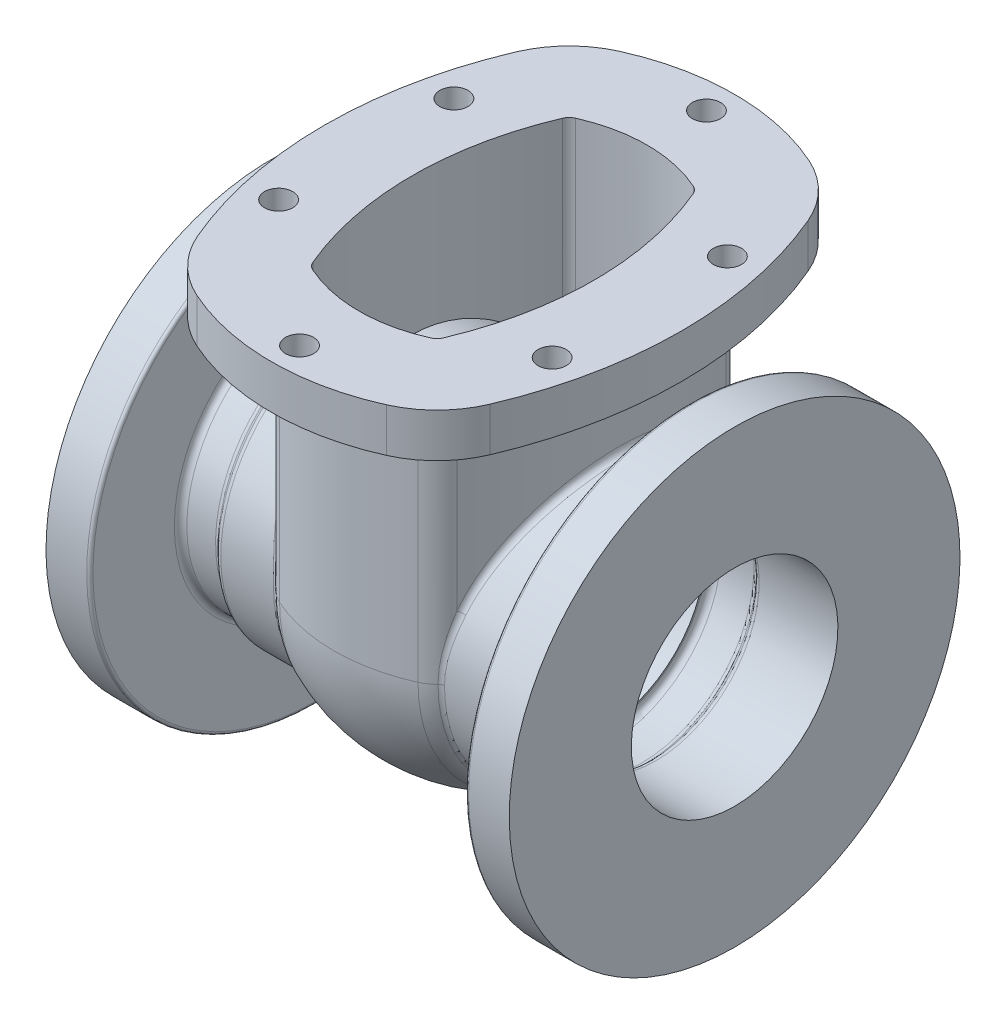
from build123d import *

# Parameters (mm, degrees)
SKETCH1_R                       = 7.14375
BOSS_EXTRUDE1_DEPTH             = 22.225
BOSS_EXTRUDE2_DEPTH             = 120.65
REVOLVE1_ANGLE                  = 180
SKETCH3_R                       = 51.59375
CUT_EXTRUDE3_DEPTH              = 288.753807533
CUT_EXTRUDE3_DEPTH_BACK         = 288.753807533
FILLET1_R                       = 3.175
BOSS_EXTRUDE3_REACH             = 289.754
SKETCH10_R                      = 73.025
SKETCH10_R_2                    = 60.325
BOSS_EXTRUDE3_DIRECTION_2_REACH = 289.754
FILLET4_R                       = 3.175


with BuildPart() as part:
    # Sketch1 → Boss-Extrude1 (new body)
    with BuildSketch(Plane(origin=(0, 0, 0), x_dir=(1, 0, 0), z_dir=(0, 1, 0))):
        with BuildLine():
            ThreePointArc((-74.058849944, -80.690921224), (-90.4875, 0), (-74.058849944, 80.690921224))
            ThreePointArc((-74.058849944, 80.690921224), (-63.584590133, 96.385165084), (-48.104977984, 107.174095369))
            ThreePointArc((-48.104977984, 107.174095369), (0, 117.475), (48.104977984, 107.174095369))
            ThreePointArc((48.104977984, 107.174095369), (63.584590133, 96.385165084), (74.058849944, 80.690921224))
            ThreePointArc((74.058849944, 80.690921224), (90.4875, 0), (74.058849944, -80.690921224))
            ThreePointArc((74.058849944, -80.690921224), (63.584590133, -96.385165084), (48.104977984, -107.174095369))
            ThreePointArc((48.104977984, -107.174095369), (0, -117.475), (-48.104977984, -107.174095369))
            ThreePointArc((-48.104977984, -107.174095369), (-63.584590133, -96.385165084), (-74.058849944, -80.690921224))
        make_face()
        with Locations(Location((0, 103.1875, 0), (0, 0, 270))):
            Circle(SKETCH1_R, mode=Mode.SUBTRACT)
        with Locations(Location((69.354092252, 44.45, 0), (0, 0, 270))):
            Circle(SKETCH1_R, mode=Mode.SUBTRACT)
        with Locations(Location((69.354092252, -44.45, 0), (0, 0, 90))):
            Circle(SKETCH1_R, mode=Mode.SUBTRACT)
        with Locations(Location((0, -103.1875, 0), (0, 0, 90))):
            Circle(SKETCH1_R, mode=Mode.SUBTRACT)
        with Locations(Location((-69.354092252, 44.45, 0), (0, 0, 90))):
            Circle(SKETCH1_R, mode=Mode.SUBTRACT)
        with Locations(Location((-69.354092252, -44.45, 0), (0, 0, 270))):
            Circle(SKETCH1_R, mode=Mode.SUBTRACT)
        with BuildLine():
            ThreePointArc((-29.903094423, 66.621734959), (0, 73.025), (29.903094423, 66.621734959))
            ThreePointArc((29.903094423, 66.621734959), (31.838045941, 65.273118673), (33.147328418, 63.311338191))
            ThreePointArc((33.147328418, 63.311338191), (46.0375, 0), (33.147328418, -63.311338191))
            ThreePointArc((33.147328418, -63.311338191), (31.838045941, -65.273118673), (29.903094423, -66.621734959))
            ThreePointArc((29.903094423, -66.621734959), (0, -73.025), (-29.903094423, -66.621734959))
            ThreePointArc((-29.903094423, -66.621734959), (-31.838045941, -65.273118673), (-33.147328418, -63.311338191))
            ThreePointArc((-33.147328418, -63.311338191), (-46.0375, 0), (-33.147328418, 63.311338191))
            ThreePointArc((-33.147328418, 63.311338191), (-31.838045941, 65.273118673), (-29.903094423, 66.621734959))
        make_face(mode=Mode.SUBTRACT)
    extrude(amount=BOSS_EXTRUDE1_DEPTH)

    # Sketch4 → Boss-Extrude2 (add)
    with BuildSketch(Plane.XZ):
        with BuildLine():
            ThreePointArc((44.836334568, -68.276933343), (58.7375, 0), (44.836334568, 68.276933343))
            ThreePointArc((44.836334568, 68.276933343), (40.908487139, 74.162274791), (35.103632583, 78.208123648))
            ThreePointArc((35.103632583, 78.208123648), (0, 85.725), (-35.103632583, 78.208123648))
            ThreePointArc((-35.103632583, 78.208123648), (-40.908487139, 74.162274791), (-44.836334568, 68.276933343))
            ThreePointArc((-44.836334568, 68.276933343), (-58.7375, 0), (-44.836334568, -68.276933343))
            ThreePointArc((-44.836334568, -68.276933343), (-40.908487139, -74.162274791), (-35.103632583, -78.208123648))
            ThreePointArc((-35.103632583, -78.208123648), (0, -85.725), (35.103632583, -78.208123648))
            ThreePointArc((35.103632583, -78.208123648), (40.908487139, -74.162274791), (44.836334568, -68.276933343))
        make_face()
        with BuildLine():
            ThreePointArc((-29.903094423, 66.621734959), (-31.838045941, 65.273118673), (-33.147328418, 63.311338191))
            ThreePointArc((-33.147328418, 63.311338191), (-46.0375, 0), (-33.147328418, -63.311338191))
            ThreePointArc((-33.147328418, -63.311338191), (-31.838045941, -65.273118673), (-29.903094423, -66.621734959))
            ThreePointArc((-29.903094423, -66.621734959), (0, -73.025), (29.903094423, -66.621734959))
            ThreePointArc((29.903094423, -66.621734959), (31.838045941, -65.273118673), (33.147328418, -63.311338191))
            ThreePointArc((33.147328418, -63.311338191), (46.0375, 0), (33.147328418, 63.311338191))
            ThreePointArc((33.147328418, 63.311338191), (31.838045941, 65.273118673), (29.903094423, 66.621734959))
            ThreePointArc((29.903094423, 66.621734959), (0, 73.025), (-29.903094423, 66.621734959))
        make_face(mode=Mode.SUBTRACT)
    extrude(amount=BOSS_EXTRUDE2_DEPTH)

    # Sketch5 → Revolve1 (revolve)
    with BuildSketch(Plane.XZ.offset(120.65)):
        with BuildLine():
            Line((58.7375, 0), (46.0375, 0))
            ThreePointArc((46.0375, 0), (42.782235956, 32.305115953), (33.147328418, 63.311338191))
            ThreePointArc((33.147328418, 63.311338191), (31.838045941, 65.273118673), (29.903094423, 66.621734959))
            ThreePointArc((29.903094423, 66.621734959), (0, 73.025), (-29.903094423, 66.621734959))
            ThreePointArc((-29.903094423, 66.621734959), (-31.838045941, 65.273118673), (-33.147328418, 63.311338191))
            ThreePointArc((-33.147328418, 63.311338191), (-42.782235956, 32.305115953), (-46.0375, 0))
            Line((-46.0375, 0), (-58.7375, 0))
            ThreePointArc((-58.7375, 0), (-55.226921129, 34.838850538), (-44.836334568, 68.276933343))
            ThreePointArc((-44.836334568, 68.276933343), (-40.908487139, 74.162274791), (-35.103632583, 78.208123648))
            ThreePointArc((-35.103632583, 78.208123648), (0, 85.725), (35.103632583, 78.208123648))
            ThreePointArc((35.103632583, 78.208123648), (40.908487139, 74.162274791), (44.836334568, 68.276933343))
            ThreePointArc((44.836334568, 68.276933343), (55.226921129, 34.838850538), (58.7375, 0))
        make_face()
    revolve(axis=Axis((58.7375, -120.65, 0), (1, 0, 0)), revolution_arc=REVOLVE1_ANGLE)

    # Sketch6 → Revolve2 (revolve)
    with BuildSketch(Plane.XY):
        with BuildLine():
            Line((96.8375, -234.95), (117.475, -234.95))
            Line((117.475, -234.95), (117.475, -173.0375))
            Line((117.475, -173.0375), (77.515128061, -173.0375))
            ThreePointArc((77.515128061, -173.0375), (76.300108163, -173.279182484), (75.27006403, -173.96743597))
            Line((75.27006403, -173.96743597), (72.36743597, -176.87006403))
            ThreePointArc((72.36743597, -176.87006403), (71.337391837, -177.558317516), (70.122371939, -177.8))
            Line((70.122371939, -177.8), (49.120888044, -177.8))
            ThreePointArc((49.120888044, -177.8), (47.073606935, -183.400045829), (44.836334568, -188.926933343))
            ThreePointArc((44.836334568, -188.926933343), (43.560758987, -191.40739219), (41.936651857, -193.675))
            Line((41.936651857, -193.675), (70.122371939, -193.675))
            ThreePointArc((70.122371939, -193.675), (71.337391837, -193.433317516), (72.36743597, -192.74506403))
            Line((72.36743597, -192.74506403), (75.27006403, -189.84243597))
            ThreePointArc((75.27006403, -189.84243597), (76.300108163, -189.154182484), (77.515128061, -188.9125))
            Line((77.515128061, -188.9125), (95.25, -188.9125))
            Line((95.25, -188.9125), (95.25, -233.3625))
            ThreePointArc((95.25, -233.3625), (95.714967985, -234.485032015), (96.8375, -234.95))
        make_face()
        with BuildLine():
            ThreePointArc((-44.836334568, -188.926933343), (-47.073606935, -183.400045829), (-49.120888044, -177.8))
            Line((-49.120888044, -177.8), (-70.122371939, -177.8))
            ThreePointArc((-70.122371939, -177.8), (-71.337391837, -177.558317516), (-72.36743597, -176.87006403))
            Line((-72.36743597, -176.87006403), (-75.27006403, -173.96743597))
            ThreePointArc((-75.27006403, -173.96743597), (-76.300108163, -173.279182484), (-77.515128061, -173.0375))
            Line((-77.515128061, -173.0375), (-117.475, -173.0375))
            Line((-117.475, -173.0375), (-117.475, -234.95))
            Line((-117.475, -234.95), (-96.8375, -234.95))
            ThreePointArc((-96.8375, -234.95), (-95.714967985, -234.485032015), (-95.25, -233.3625))
            Line((-95.25, -233.3625), (-95.25, -188.9125))
            Line((-95.25, -188.9125), (-77.515128061, -188.9125))
            ThreePointArc((-77.515128061, -188.9125), (-76.300108163, -189.154182484), (-75.27006403, -189.84243597))
            Line((-75.27006403, -189.84243597), (-72.36743597, -192.74506403))
            ThreePointArc((-72.36743597, -192.74506403), (-71.337391837, -193.433317516), (-70.122371939, -193.675))
            Line((-70.122371939, -193.675), (-41.936651857, -193.675))
            ThreePointArc((-41.936651857, -193.675), (-43.560758987, -191.40739219), (-44.836334568, -188.926933343))
        make_face()
    revolve(axis=Axis((0, -120.65, 0), (1, 0, 0)))

    # Sketch3 → Cut-Extrude3 (cut, two sides)
    with BuildSketch(Plane(origin=(0, 0, 0), x_dir=(0, 0, -1), z_dir=(1, 0, 0))) as cut_extrude3_sk:
        with Locations((0, -120.65)):
            Circle(SKETCH3_R)
    extrude(amount=CUT_EXTRUDE3_DEPTH, mode=Mode.SUBTRACT)
    extrude(cut_extrude3_sk.sketch, amount=-CUT_EXTRUDE3_DEPTH_BACK, mode=Mode.SUBTRACT)

    # Fillet1
    fillet1_edges = [part.edges().sort_by_distance(p)[0] for p in [
        (49.120888044, -161.061152545, -40.411152545),
        (58.737500008, -63.500000001, -3e-07),
        (-49.120888044, -161.061152545, 40.411152545),
        (-58.737500001, -63.500000011, 3e-07),
    ]]
    fillet(fillet1_edges, radius=FILLET1_R)

    # Sketch10 → Boss-Extrude3 (add, up to next)
    with BuildSketch(Plane(origin=(0, 0, 0), x_dir=(0, 0, -1), z_dir=(1, 0, 0)), mode=Mode.PRIVATE) as boss_extrude3_sk1:
        with Locations(Location((0, -120.65, 0), (0, 0, 270))):
            Circle(SKETCH10_R)
        with Locations((0, -120.65)):
            Circle(SKETCH10_R_2, mode=Mode.SUBTRACT)
    boss_extrude3_tool1 = extrude(boss_extrude3_sk1.sketch, amount=-BOSS_EXTRUDE3_REACH, mode=Mode.PRIVATE) - part.part
    add(boss_extrude3_tool1.solids().sort_by_distance((0, -49.690459, 0))[0])

    # Sketch10 → Boss-Extrude3 direction 2 (add, up to next)
    with BuildSketch(Plane(origin=(0, 0, 0), x_dir=(0, 0, -1), z_dir=(1, 0, 0)), mode=Mode.PRIVATE) as boss_extrude3_direction_2_sk1:
        with Locations(Location((0, -120.65, 0), (0, 0, 270))):
            Circle(SKETCH10_R)
        with Locations((0, -120.65)):
            Circle(SKETCH10_R_2, mode=Mode.SUBTRACT)
    boss_extrude3_direction_2_tool1 = extrude(boss_extrude3_direction_2_sk1.sketch, amount=BOSS_EXTRUDE3_DIRECTION_2_REACH, mode=Mode.PRIVATE) - part.part
    add(boss_extrude3_direction_2_tool1.solids().sort_by_distance((0, -49.690459, 0))[0])

    # Fillet4
    fillet4_edges = [part.edges().sort_by_distance(p)[0] for p in [
        (42.863046206, -107.431253504, -71.818628266),
        (58.7375, -47.625, 0),
        (42.863046201, -107.431253503, 71.818628268),
        (41.936651857, -172.286472696, 51.636472696),
        (95.25, -52.3875, 0),
        (-42.863046206, -107.431253504, -71.818628266),
        (-58.7375, -47.625, 0),
        (-42.863046202, -107.431253503, 71.818628268),
        (-41.936651857, -172.286472696, 51.636472696),
        (-95.25, -52.3875, 0),
    ]]
    fillet(fillet4_edges, radius=FILLET4_R)


solid = part.part
